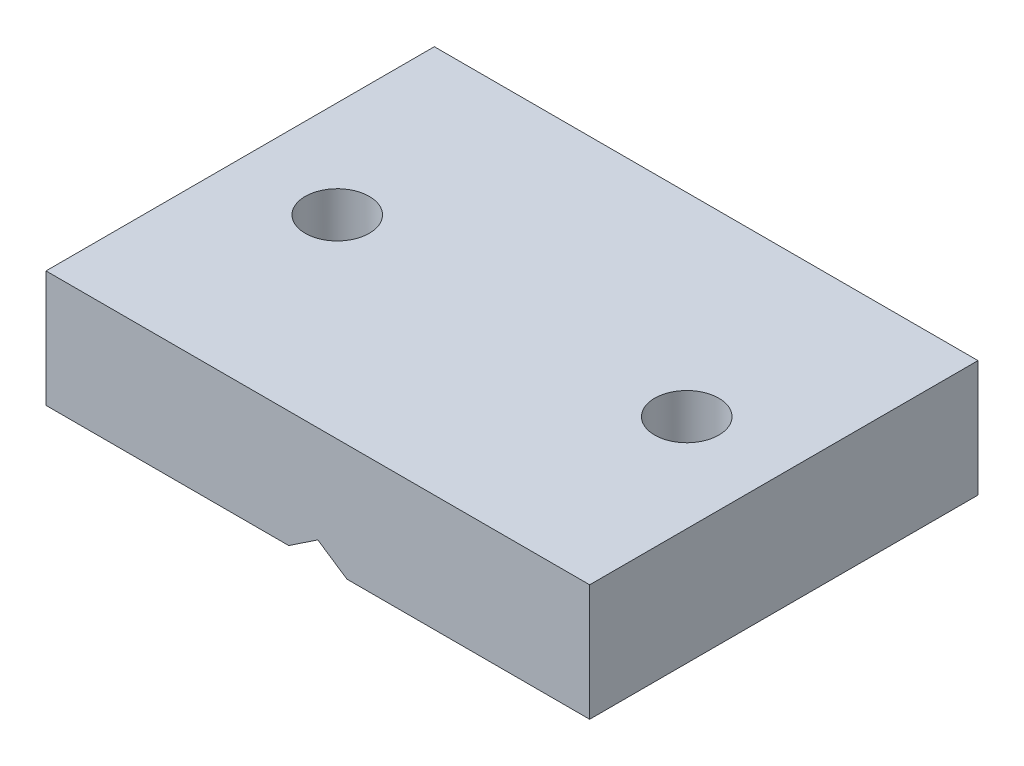
from build123d import *

# Parameters (mm, degrees)
RESSALTO_EXTRUS_O1_DEPTH = 10
ESBO_O2_R                = 1.65
CORTE_EXTRUS_O1_DEPTH    = 15


with BuildPart() as part:
    # Esboço1 → Ressalto-extrusão1 (new body, symmetric)
    with BuildSketch(Plane.XY):
        Polygon((-1.5, 0), (-14, 0), (-14, 6), (14, 6), (14, 0), (1.5, 0), (0, 1), align=None)
    extrude(amount=RESSALTO_EXTRUS_O1_DEPTH, both=True)

    # Esboço2 → Corte-extrusão1 (cut)
    with BuildSketch(Plane.XZ):
        with Locations((-9, 0)):
            Circle(ESBO_O2_R)
        with Locations((9, 0)):
            Circle(ESBO_O2_R)
    extrude(amount=-CORTE_EXTRUS_O1_DEPTH, mode=Mode.SUBTRACT)


solid = part.part
